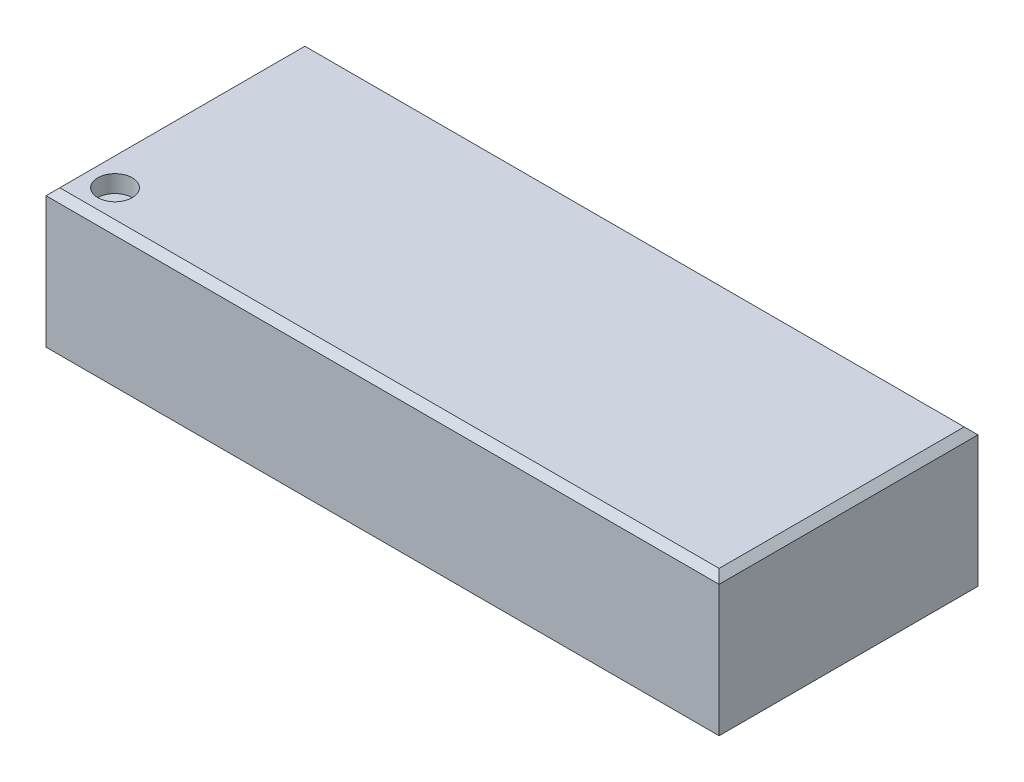
from build123d import *

# Parameters (mm, degrees)
ESQUISSE1_W             = 9.75
ESQUISSE1_H             = 3.75
BOSS_EXTRU_1_DEPTH      = 2
ESQUISSE2_R             = 0.25
ENL_V_MAT_EXTRU_1_DEPTH = 0.25
CHANFREIN1_SIZE         = 0.1


with BuildPart() as part:
    # Esquisse1 → Boss.-Extru.1 (new body)
    with BuildSketch(Plane(origin=(0, 0, 0), x_dir=(1, 0, 0), z_dir=(0, 1, 0))):
        Rectangle(ESQUISSE1_W, ESQUISSE1_H)
    extrude(amount=BOSS_EXTRU_1_DEPTH)

    # Esquisse2 → Enlèv. mat.-Extru.1 (cut)
    with BuildSketch(Plane(origin=(0, 2, 0), x_dir=(1, 0, 0), z_dir=(0, 1, 0))):
        with Locations(Location((-4.375, -1.375, 0), (0, 0, 270))):  # turned: the seam where the file's is
            Circle(ESQUISSE2_R)
    extrude(amount=-ENL_V_MAT_EXTRU_1_DEPTH, mode=Mode.SUBTRACT)

    # Chanfrein1
    chanfrein1_edges = [part.edges().sort_by_distance(p)[0] for p in [
        (4.875, 2, 0),
        (0, 2, -1.875),
        (-4.875, 2, 0),
        (0, 2, 1.875),
    ]]
    chamfer(chanfrein1_edges, length=CHANFREIN1_SIZE)


solid = part.part
